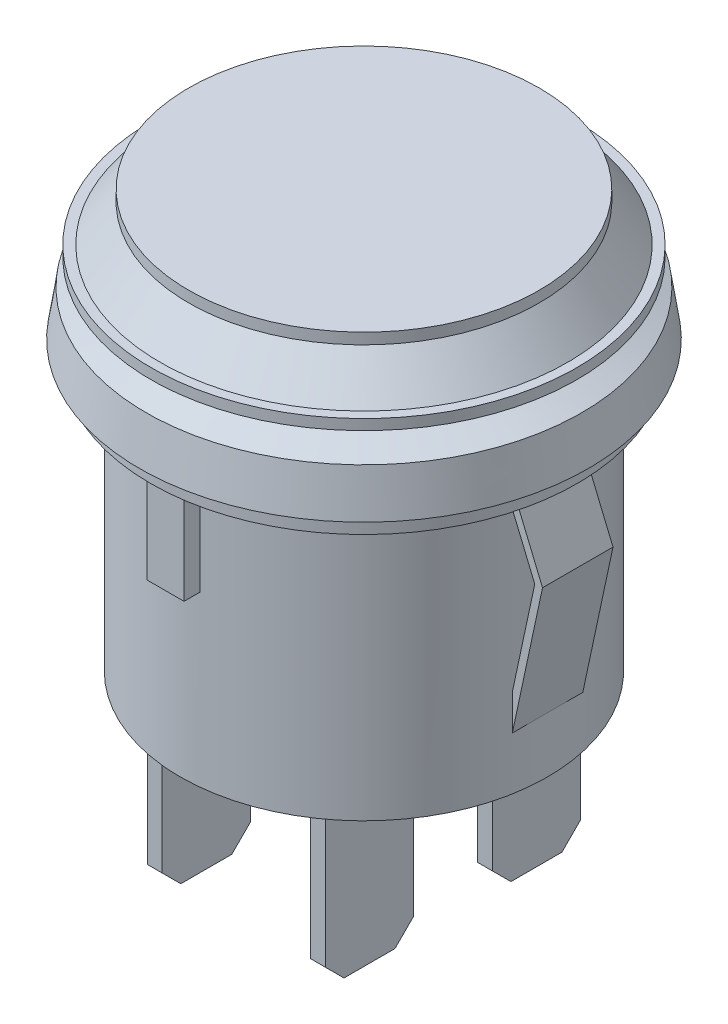
from build123d import *

# Parameters (mm, degrees)
SKETCH1_R             = 9.9
BOSS_EXTRUDE1_DEPTH   = 14.5
SKETCH2_R             = 11.5
BOSS_EXTRUDE2_DEPTH   = 1
BOSS_EXTRUDE3_REACH   = 24.2
SKETCH3_W             = 2
SKETCH3_H             = 5.4
BOSS_EXTRUDE4_DEPTH   = 1.9
BOSS_EXTRUDE4_2_DEPTH = 1.9
SKETCH6_W             = 0.8
SKETCH6_H             = 4.75
BOSS_EXTRUDE5_DEPTH   = 9
CHAMFER1_SIZE         = 1


with BuildPart() as part:
    # Sketch1 → Boss-Extrude1 (new body)
    with BuildSketch(Plane(origin=(0, 0, 0), x_dir=(1, 0, 0), z_dir=(0, 1, 0))):
        Circle(SKETCH1_R)
    extrude(amount=BOSS_EXTRUDE1_DEPTH)

    # Sketch2 → Boss-Extrude2 (add)
    with BuildSketch(Plane(origin=(0, 14.5, 0), x_dir=(1, 0, 0), z_dir=(0, 1, 0))):
        Circle(SKETCH2_R)
    extrude(amount=BOSS_EXTRUDE2_DEPTH)

    # Sketch3 → Boss-Extrude3 (add, up to next)
    with BuildSketch(Plane.XY.offset(10.7), mode=Mode.PRIVATE) as boss_extrude3_sk1:
        with Locations((0, 11.8)):
            Rectangle(SKETCH3_W, SKETCH3_H)
    boss_extrude3_tool1 = extrude(boss_extrude3_sk1.sketch, amount=-BOSS_EXTRUDE3_REACH, mode=Mode.PRIVATE) - part.part
    add(boss_extrude3_tool1.solids().sort_by_distance((0, 11.8, 10.7))[0])

    # Sketch5 → Revolve1 (revolve)
    with BuildSketch(Plane.XY):
        Polygon((-12.1, 15.5), (0, 15.5), (0, 22.5), (-9.45, 22.5), (-9.45, 21.906088168), (-10.98819494, 19.904143901), (-11.482792935, 19.904143901), (-11.482792935, 19.338889049), (-9.45, 18.938500196), (-11.741868076, 17.92575192), align=None)
    revolve(axis=Axis((0, 0, 0), (0, 1, 0)))

    # Sketch6 → Boss-Extrude5 (add)
    with BuildSketch(Plane.XZ):
        with Locations((-4.4, 4.5)):
            Rectangle(SKETCH6_W, SKETCH6_H)
        with Locations((-4.4, -4.5)):
            Rectangle(SKETCH6_W, SKETCH6_H)
        with Locations((4.4, 4.5)):
            Rectangle(SKETCH6_W, SKETCH6_H)
        with Locations((4.4, -4.5)):
            Rectangle(SKETCH6_W, SKETCH6_H)
    extrude(amount=BOSS_EXTRUDE5_DEPTH)

    # Chamfer1
    chamfer1_edges = [part.edges().sort_by_distance(p)[0] for p in [
        (-4.4, -9, 2.125),
        (-4.4, -9, 6.875),
        (-4.4, -9, -6.875),
        (-4.4, -9, -2.125),
        (4.4, -9, 2.125),
        (4.4, -9, 6.875),
        (4.4, -9, -6.875),
        (4.4, -9, -2.125),
    ]]
    chamfer(chamfer1_edges, length=CHAMFER1_SIZE)


with BuildPart() as body_2:
    # Sketch4 → Boss-Extrude4 (new body, symmetric)
    with BuildSketch(Plane.XY):
        Polygon((-9.9, 14.5), (-11.528661289, 10.6), (-9.9, 3), (-9.9, 4.908942102), (-11.111306166, 10.56139232), (-9.9, 13.461991774), align=None)
    extrude(amount=BOSS_EXTRUDE4_DEPTH, both=True)


with BuildPart() as body_3:
    # Sketch4 → Boss-Extrude4 2 (new body, symmetric)
    with BuildSketch(Plane.XY):
        Polygon((9.9, 13.461991774), (9.9, 14.5), (11.528661289, 10.6), (9.9, 3), (9.9, 4.908942102), (11.111306166, 10.56139232), align=None)
    extrude(amount=BOSS_EXTRUDE4_2_DEPTH, both=True)


solid = Compound([part.part, body_2.part, body_3.part])
